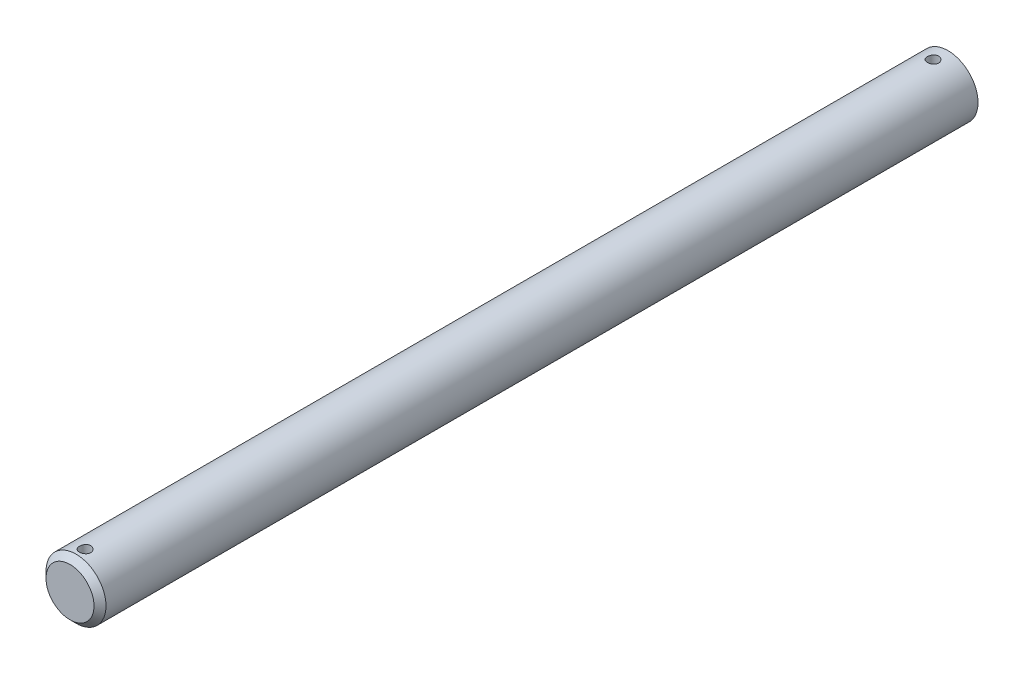
from build123d import *

# Parameters (mm, degrees)
SKETCH3_R               = 3.175
BOSS_EXTRUDE1_DEPTH     = 304.8
CHAMFER1_SIZE           = 0.635
CUT_EXTRUDE1_START      = -92.927050112
SKETCH4_R               = 3.175
CUT_EXTRUDE1_DEPTH      = 517.672949888
SKETCH5_R               = 0.5953125
CUT_EXTRUDE2_DEPTH      = 4.175
CUT_EXTRUDE2_DEPTH_BACK = 4.175


with BuildPart() as part:
    # Sketch3 → Boss-Extrude1 (new body, symmetric)
    with BuildSketch(Plane.XY):
        Circle(SKETCH3_R)
    extrude(amount=BOSS_EXTRUDE1_DEPTH, both=True)

    # Chamfer1
    chamfer1_edges = [part.edges().sort_by_distance(p)[0] for p in [
        (-3.175, 0, -304.8),
        (-3.175, 0, 304.8),
    ]]
    chamfer(chamfer1_edges, length=CHAMFER1_SIZE)

    # Sketch4 → Cut-Extrude1 (cut, through all)
    with BuildSketch(Plane.XY.offset(304.8).offset(CUT_EXTRUDE1_START)):
        Circle(SKETCH4_R)
    extrude(amount=-CUT_EXTRUDE1_DEPTH, mode=Mode.SUBTRACT)

    # Sketch5 → Cut-Extrude2 (cut, two sides)
    with BuildSketch(Plane(origin=(0, 0, 0), x_dir=(1, 0, 0), z_dir=(0, 1, 0))) as cut_extrude2_sk:
        with Locations((0, -213.460449888)):
            Circle(SKETCH5_R)
        with Locations((0, -303.2125)):
            Circle(SKETCH5_R)
    extrude(amount=CUT_EXTRUDE2_DEPTH, mode=Mode.SUBTRACT)
    extrude(cut_extrude2_sk.sketch, amount=-CUT_EXTRUDE2_DEPTH_BACK, mode=Mode.SUBTRACT)


solid = part.part
